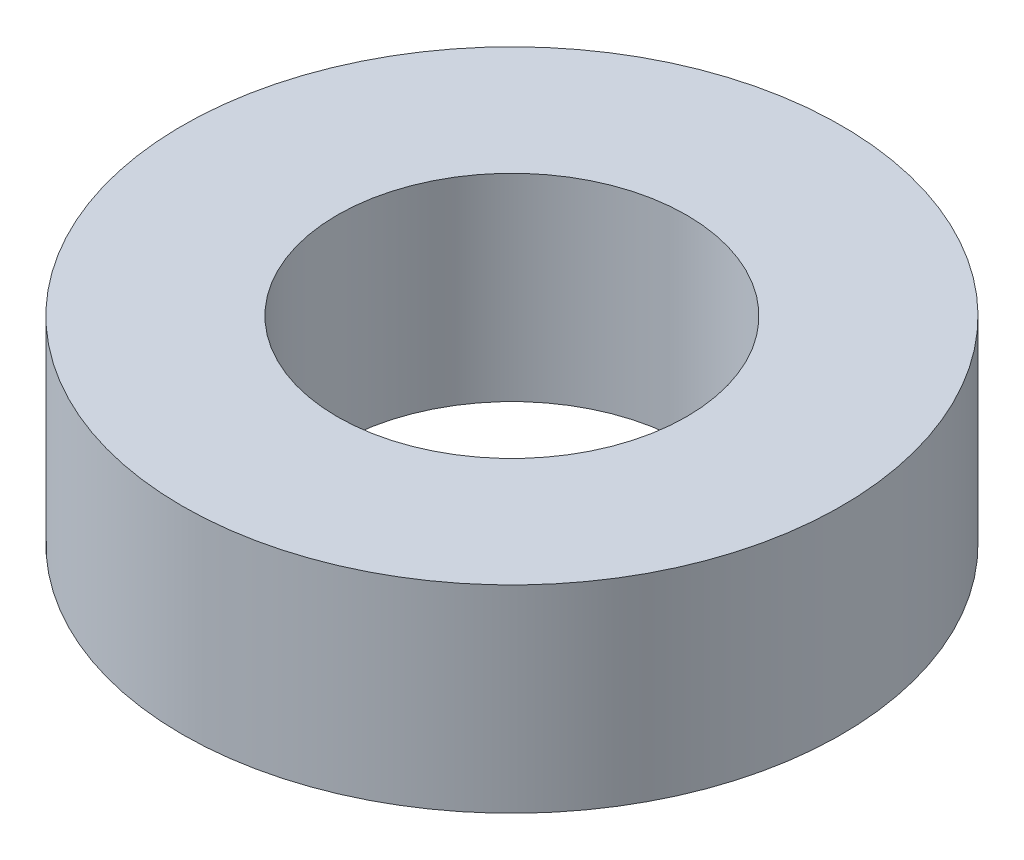
from build123d import *

# Parameters (mm, degrees)
SKETCH1_R           = 5
SKETCH1_R_2         = 2.65
BOSS_EXTRUDE1_DEPTH = 3


with BuildPart() as part:
    # Sketch1 → Boss-Extrude1 (new body)
    with BuildSketch(Plane(origin=(0, 0, 0), x_dir=(1, 0, 0), z_dir=(0, 1, 0))):
        Circle(SKETCH1_R)
        Circle(SKETCH1_R_2, mode=Mode.SUBTRACT)
    extrude(amount=BOSS_EXTRUDE1_DEPTH)


solid = part.part
